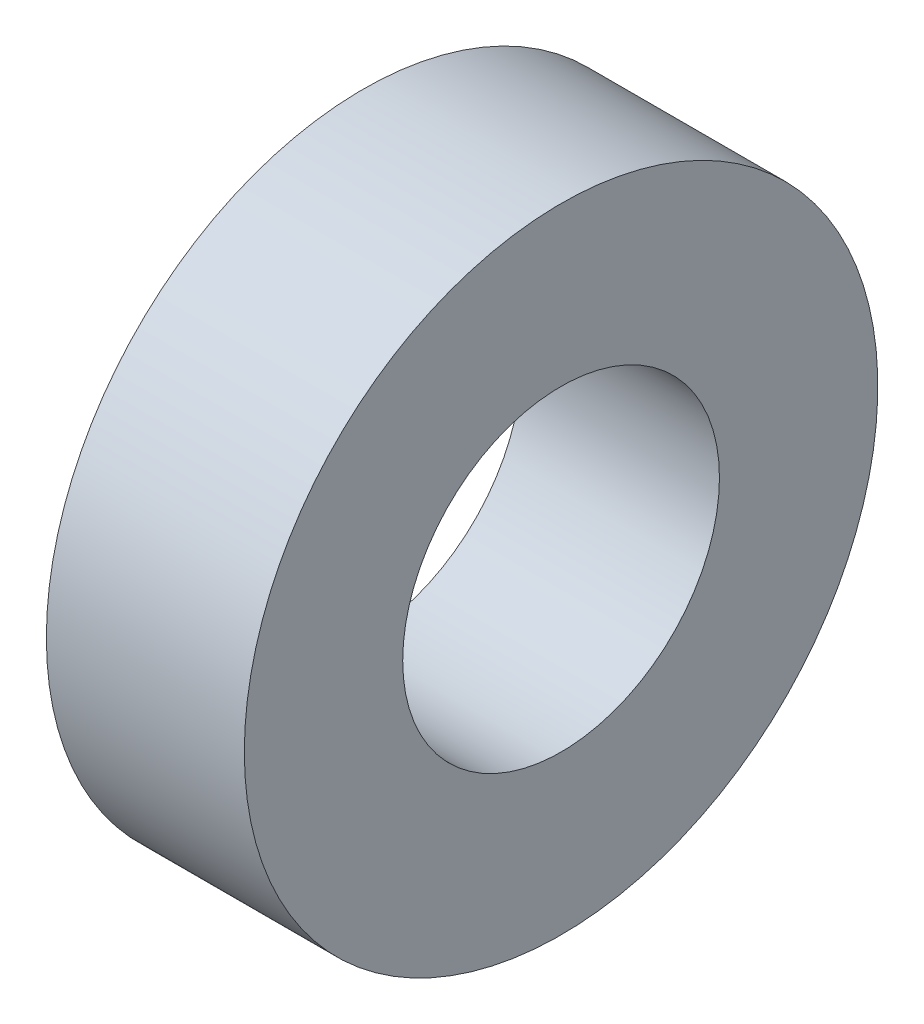
from build123d import *

# Parameters (mm, degrees)
SKETCH1_W = 5
SKETCH1_H = 4


with BuildPart() as part:
    # Sketch1 → Revolve1 (revolve)
    with BuildSketch(Plane.XY):
        with Locations((2.5, 6)):
            Rectangle(SKETCH1_W, SKETCH1_H)
    revolve(axis=Axis((-188.192192496, 0, 0), (1, 0, 0)))


solid = part.part
